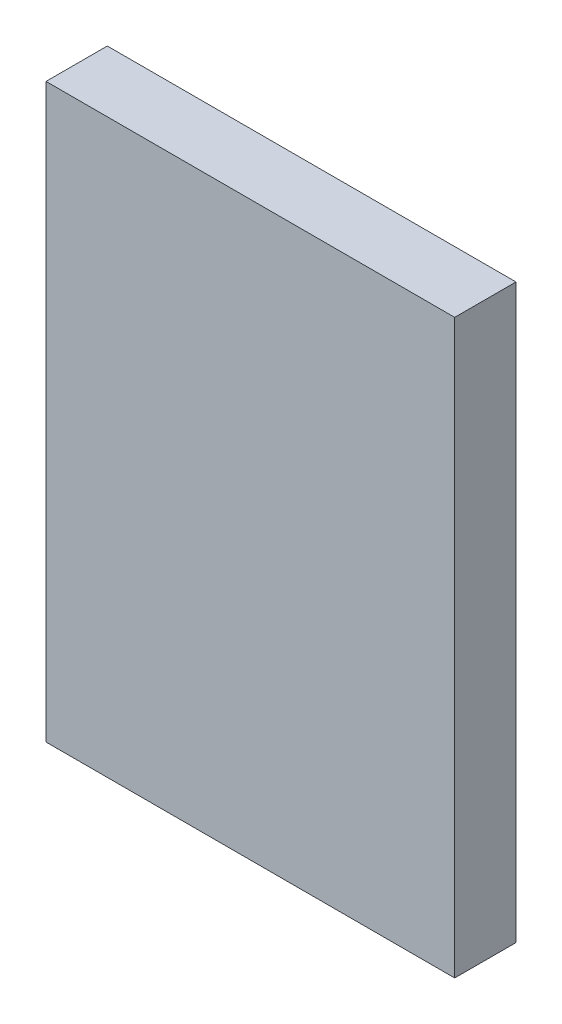
from build123d import *

# Parameters (mm, degrees)
SKETCH_2_W      = 40
SKETCH_2_H      = 56
EXTRUDE_1_DEPTH = 6


with BuildPart() as part:
    # Эскиз2 → Бобышка-Вытянуть1 (new body)
    with BuildSketch(Plane.XY):
        with Locations((0, -20)):
            Rectangle(SKETCH_2_W, SKETCH_2_H)
    extrude(amount=EXTRUDE_1_DEPTH)


solid = part.part
